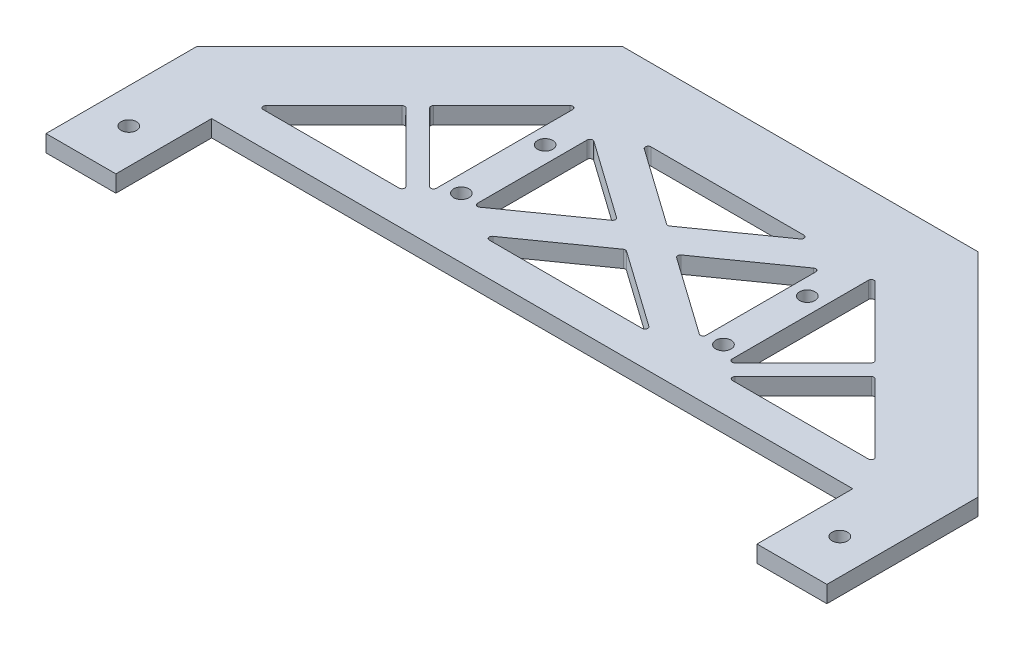
from build123d import *

# Parameters (mm, degrees)
SKETCH1_R           = 1.375
BOSS_EXTRUDE1_DEPTH = 3


with BuildPart() as part:
    # Sketch1 → Boss-Extrude1 (new body)
    with BuildSketch(Plane(origin=(0, 0, 0), x_dir=(1, 0, 0), z_dir=(0, 1, 0))):
        Polygon((12.5, 17.135), (127.2, 17.135), (127.2, 0), (139.7, 0), (139.7, 17.135), (139.7, 27.03449494), (101.68231227, 65.05218267), (38.01768773, 65.05218267), (0, 27.03449494), (0, 17.135), (0, 0), (12.5, 0), align=None)
        with Locations((6.25, 8.5675)):
            Circle(SKETCH1_R, mode=Mode.SUBTRACT)
        with Locations((133.45, 8.5675)):
            Circle(SKETCH1_R, mode=Mode.SUBTRACT)
        with Locations((46.402464035, 27.89462575)):
            Circle(SKETCH1_R, mode=Mode.SUBTRACT)
        with Locations((46.402464035, 42.89462575)):
            Circle(SKETCH1_R, mode=Mode.SUBTRACT)
        with Locations((93.297535965, 27.89462575)):
            Circle(SKETCH1_R, mode=Mode.SUBTRACT)
        with Locations((93.297535965, 42.89462575)):
            Circle(SKETCH1_R, mode=Mode.SUBTRACT)
        with BuildLine():
            Line((55.883073513, 24.04324829), (69.561324865, 33.715232576))
            ThreePointArc((69.561324865, 33.715232576), (69.85, 33.806984285), (70.138675135, 33.715232576))
            Line((70.138675135, 33.715232576), (83.816926487, 24.04324829))
            ThreePointArc((83.816926487, 24.04324829), (84.004761659, 23.483547277), (83.528251352, 23.135))
            Line((83.528251352, 23.135), (56.171748648, 23.135))
            ThreePointArc((56.171748648, 23.135), (55.695238341, 23.483547277), (55.883073513, 24.04324829))
        make_face(mode=Mode.SUBTRACT)
        with BuildLine():
            Line((49.40246404, 27.77516044), (49.40246404, 47.41202223))
            ThreePointArc((49.40246404, 47.41202223), (49.672613618, 47.856059147), (50.191139175, 47.82027052))
            Line((50.191139175, 47.82027052), (64.076497308, 38.001839625))
            ThreePointArc((64.076497308, 38.001839625), (64.287822173, 37.593591335), (64.076497308, 37.185343045))
            Line((64.076497308, 37.185343045), (50.191139175, 27.36691215))
            ThreePointArc((50.191139175, 27.36691215), (49.672613618, 27.331123523), (49.40246404, 27.77516044))
        make_face(mode=Mode.SUBTRACT)
        with BuildLine():
            Line((56.171748648, 52.05218267), (83.528251352, 52.05218267))
            ThreePointArc((83.528251352, 52.05218267), (84.004761659, 51.703635393), (83.816926487, 51.14393438))
            Line((83.816926487, 51.14393438), (70.138675135, 41.471950094))
            ThreePointArc((70.138675135, 41.471950094), (69.85, 41.380198385), (69.561324865, 41.471950094))
            Line((69.561324865, 41.471950094), (55.883073513, 51.14393438))
            ThreePointArc((55.883073513, 51.14393438), (55.695238341, 51.703635393), (56.171748648, 52.05218267))
        make_face(mode=Mode.SUBTRACT)
        with BuildLine():
            Line((90.29753596, 27.77516044), (90.29753596, 47.41202223))
            ThreePointArc((90.29753596, 47.41202223), (90.027386382, 47.856059147), (89.508860825, 47.82027052))
            Line((89.508860825, 47.82027052), (75.623502692, 38.001839625))
            ThreePointArc((75.623502692, 38.001839625), (75.412177827, 37.593591335), (75.623502692, 37.185343045))
            Line((75.623502692, 37.185343045), (89.508860825, 27.36691215))
            ThreePointArc((89.508860825, 27.36691215), (90.027386382, 27.331123523), (90.29753596, 27.77516044))
        make_face(mode=Mode.SUBTRACT)
        with BuildLine():
            Line((15.692388152, 23.135), (40.04777251, 23.135))
            ThreePointArc((40.04777251, 23.135), (40.509712276, 23.443658284), (40.4013259, 23.988553391))
            Line((40.4013259, 23.988553391), (28.223633721, 36.166245569))
            ThreePointArc((28.223633721, 36.166245569), (27.870080331, 36.312692179), (27.51652694, 36.166245569))
            Line((27.51652694, 36.166245569), (15.338834761, 23.988553391))
            ThreePointArc((15.338834761, 23.988553391), (15.230448386, 23.443658284), (15.692388152, 23.135))
        make_face(mode=Mode.SUBTRACT)
        with BuildLine():
            Line((30.344954065, 38.994672694), (42.548910644, 51.198629273))
            ThreePointArc((42.548910644, 51.198629273), (43.093805751, 51.307015649), (43.402464035, 50.845075883))
            Line((43.402464035, 50.845075883), (43.402464035, 26.437162724))
            ThreePointArc((43.402464035, 26.437162724), (43.093805751, 25.975222958), (42.548910644, 26.083609334))
            Line((42.548910644, 26.083609334), (30.344954065, 38.287565913))
            ThreePointArc((30.344954065, 38.287565913), (30.198507456, 38.641119304), (30.344954065, 38.994672694))
        make_face(mode=Mode.SUBTRACT)
        with BuildLine():
            Line((109.355045935, 38.994672694), (97.151089356, 51.198629273))
            ThreePointArc((97.151089356, 51.198629273), (96.606194249, 51.307015649), (96.297535965, 50.845075883))
            Line((96.297535965, 50.845075883), (96.297535965, 26.437162724))
            ThreePointArc((96.297535965, 26.437162724), (96.606194249, 25.975222958), (97.151089356, 26.083609334))
            Line((97.151089356, 26.083609334), (109.355045935, 38.287565913))
            ThreePointArc((109.355045935, 38.287565913), (109.501492544, 38.641119304), (109.355045935, 38.994672694))
        make_face(mode=Mode.SUBTRACT)
        with BuildLine():
            Line((124.361165239, 23.988553391), (112.18347306, 36.166245569))
            ThreePointArc((112.18347306, 36.166245569), (111.829919669, 36.312692179), (111.476366279, 36.166245569))
            Line((111.476366279, 36.166245569), (99.2986741, 23.988553391))
            ThreePointArc((99.2986741, 23.988553391), (99.190287724, 23.443658284), (99.65222749, 23.135))
            Line((99.65222749, 23.135), (124.007611848, 23.135))
            ThreePointArc((124.007611848, 23.135), (124.469551614, 23.443658284), (124.361165239, 23.988553391))
        make_face(mode=Mode.SUBTRACT)
    extrude(amount=BOSS_EXTRUDE1_DEPTH)


solid = part.part
